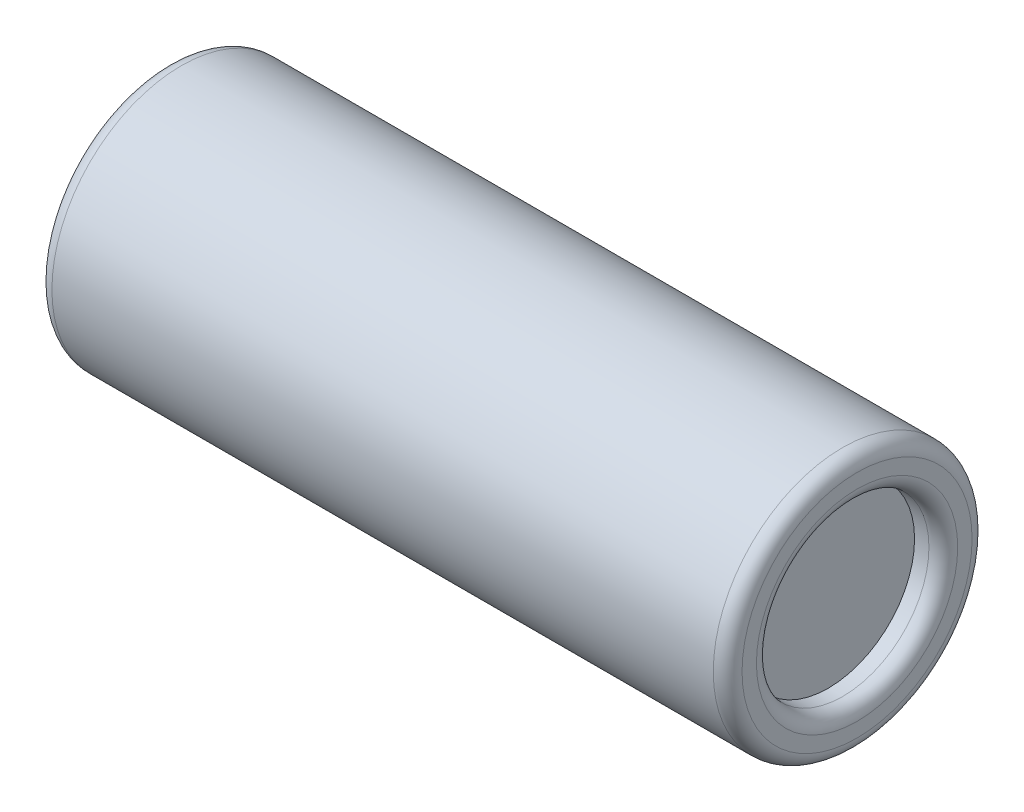
from build123d import *

# Parameters (mm, degrees)
SKETCH1_R      = 4.5
EXTRUDE1_DEPTH = 24
FILLET1_R      = 0.5
SKETCH2_R      = 3
EXTRUDE2_DEPTH = 1
FILLET2_R      = 0.5


with BuildPart() as part:
    # Sketch1 → Extrude1 (new body)
    with BuildSketch(Plane(origin=(0, 0, 0), x_dir=(0, 0, -1), z_dir=(1, 0, 0))):
        Circle(SKETCH1_R)
    extrude(amount=EXTRUDE1_DEPTH)

    # Fillet1
    fillet1_edges = [part.edges().sort_by_distance(p)[0] for p in [
        (0, 0, 4.5),
    ]]
    fillet(fillet1_edges, radius=FILLET1_R)

    # Sketch2 → Extrude2 (cut)
    with BuildSketch(Plane(origin=(24, 0, 0), x_dir=(0, 0, -1), z_dir=(1, 0, 0))):
        Circle(SKETCH2_R)
    extrude(amount=-EXTRUDE2_DEPTH, mode=Mode.SUBTRACT)

    # Fillet2
    fillet2_edges = [part.edges().sort_by_distance(p)[0] for p in [
        (24, 0, 4.5),
        (24, 0, 3),
    ]]
    fillet(fillet2_edges, radius=FILLET2_R)


solid = part.part
